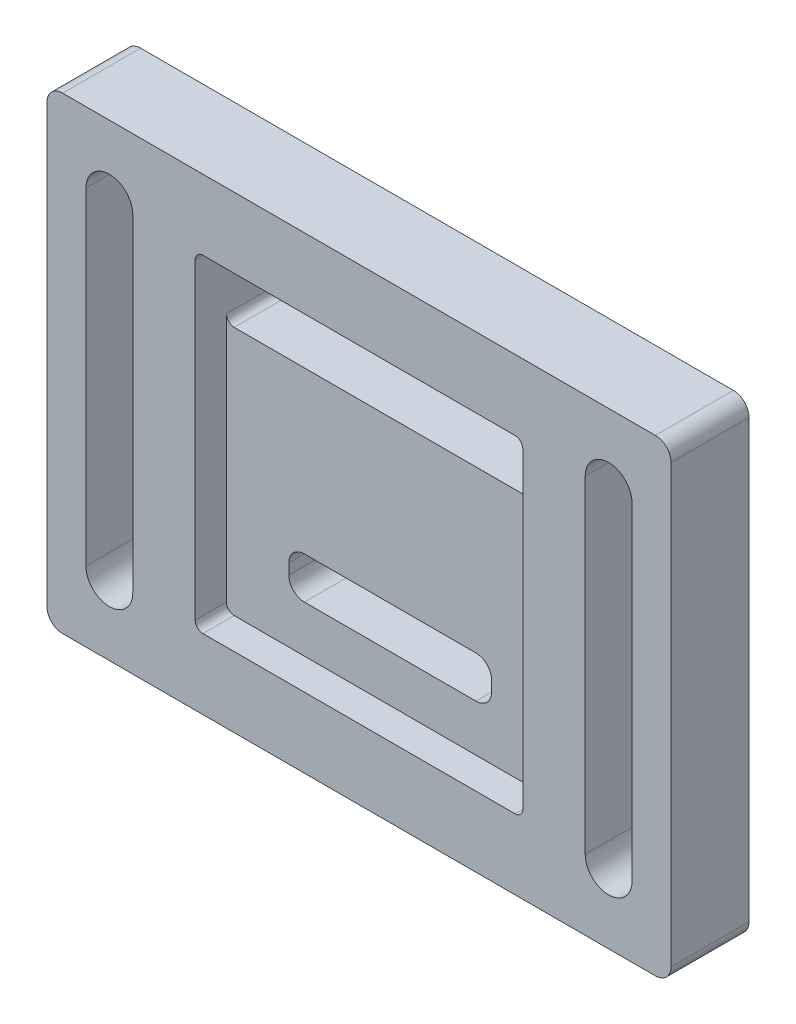
from build123d import *

# Parameters (mm, degrees)
SCHIZZO2_W                   = 40
SCHIZZO2_H                   = 30
ESTRUSIONE_ESTRUSIONE1_DEPTH = 5
SCHIZZO2_3_W                 = 21
SCHIZZO2_3_H                 = 16
SCHIZZO2_3_W_2               = 13
SCHIZZO2_3_H_2               = 2.673538732
ESTRUSIONE_ESTRUSIONE2_DEPTH = 3
RACCORDO2_R                  = 1
RACCORDO3_R                  = 1
RACCORDO4_R                  = 0.5


with BuildPart() as part:
    # Schizzo2 → Estrusione-Estrusione1 (new body)
    with BuildSketch(Plane.XY):
        with Locations((20, 15)):
            Rectangle(SCHIZZO2_W, SCHIZZO2_H)
        with BuildLine():
            ThreePointArc((2.5, 25.5), (4, 27), (5.5, 25.5))
            Line((5.5, 25.5), (5.5, 4.5))
            ThreePointArc((5.5, 4.5), (4, 3), (2.5, 4.5))
            Line((2.5, 4.5), (2.5, 25.5))
        make_face(mode=Mode.SUBTRACT)
        Polygon((9.5, 20.5), (9.5, 25.5), (30.5, 25.5), (30.5, 20.5), (30.5, 4.5), (9.5, 4.5), align=None, mode=Mode.SUBTRACT)
        with BuildLine():
            ThreePointArc((34.5, 25.5), (36, 27), (37.5, 25.5))
            Line((37.5, 25.5), (37.5, 4.5))
            ThreePointArc((37.5, 4.5), (36, 3), (34.5, 4.5))
            Line((34.5, 4.5), (34.5, 25.5))
        make_face(mode=Mode.SUBTRACT)
    extrude(amount=ESTRUSIONE_ESTRUSIONE1_DEPTH)

    # Schizzo2_3 → Estrusione-Estrusione2 (add)
    with BuildSketch(Plane.XY):
        with Locations((20, 12.5)):
            Rectangle(SCHIZZO2_3_W, SCHIZZO2_3_H)
        with Locations((20, 8.836769366)):
            Rectangle(SCHIZZO2_3_W_2, SCHIZZO2_3_H_2, mode=Mode.SUBTRACT)
    extrude(amount=ESTRUSIONE_ESTRUSIONE2_DEPTH)

    # Raccordo2
    raccordo2_edges = [part.edges().sort_by_distance(p)[0] for p in [
        (13.5, 10.173538732, 1.5),
        (26.5, 10.173538732, 1.5),
        (26.5, 7.5, 1.5),
        (13.5, 7.5, 1.5),
    ]]
    fillet(raccordo2_edges, radius=RACCORDO2_R)

    # Raccordo3
    raccordo3_edges = [part.edges().sort_by_distance(p)[0] for p in [
        (0, 30, 2.5),
        (40, 30, 2.5),
        (40, 0, 2.5),
        (0, 0, 2.5),
    ]]
    fillet(raccordo3_edges, radius=RACCORDO3_R)

    # Raccordo4
    raccordo4_edges = [part.edges().sort_by_distance(p)[0] for p in [
        (30.5, 20.5, 1.5),
        (9.5, 20.5, 1.5),
        (30.5, 25.5, 2.5),
        (9.5, 25.5, 2.5),
        (30.5, 4.5, 4),
        (9.5, 4.5, 4),
    ]]
    fillet(raccordo4_edges, radius=RACCORDO4_R)


solid = part.part
